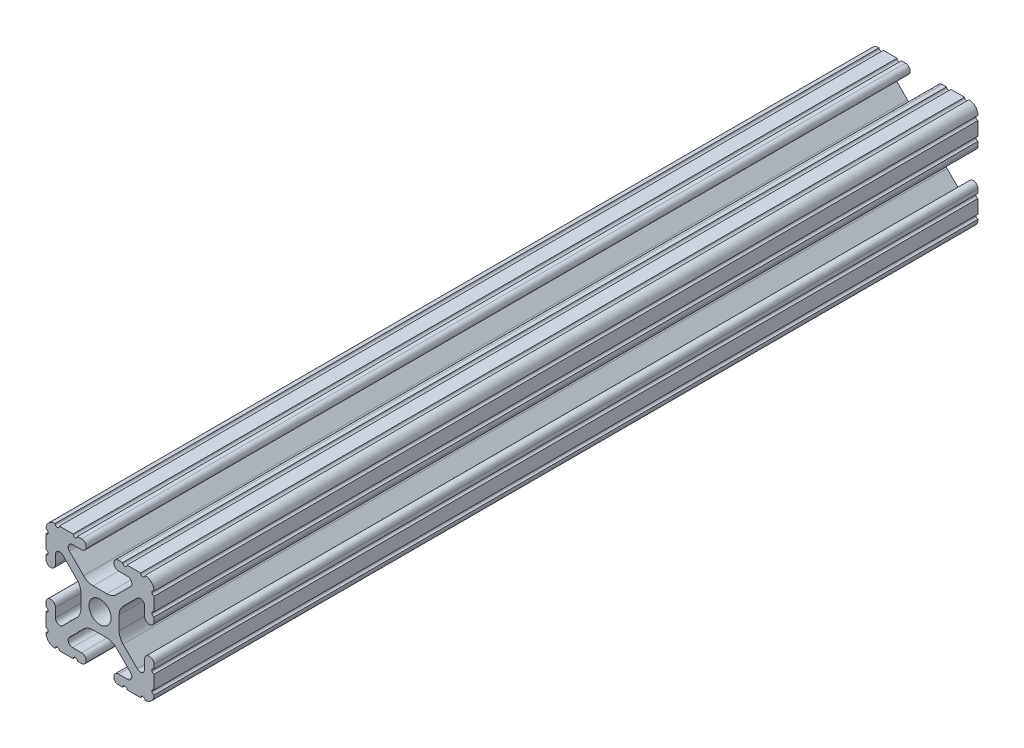
from build123d import *

# Parameters (mm, degrees)
SKETCH1_R           = 2.6035
BOSS_EXTRUDE1_DEPTH = 96.8756


with BuildPart() as part:
    # Sketch1 → Boss-Extrude1 (new body, symmetric)
    with BuildSketch(Plane(origin=(0, 0, -450.85), x_dir=(-1, 0, 0), z_dir=(0, 0, -1))):
        with BuildLine():
            Line((12.7, -9.5504), (12.7, -6.3330836))
            ThreePointArc((12.7, -6.3330836), (12.192, -5.8250836), (12.7, -5.3170836))
            Line((12.7, -5.3170836), (12.7, -4.3434))
            ThreePointArc((12.7, -4.3434), (11.5951, -3.2385), (10.4902, -4.3434))
            Line((10.4902, -4.3434), (10.4902, -6.474794456))
            ThreePointArc((10.4902, -6.474794456), (9.863006367, -7.413456061), (8.75577951, -7.193214945))
            Line((8.75577951, -7.193214945), (5.42573597, -3.863171405))
            ThreePointArc((5.42573597, -3.863171405), (4.737482484, -2.833127272), (4.4958, -1.618107374))
            Line((4.4958, -1.618107374), (4.4958, 1.618107374))
            ThreePointArc((4.4958, 1.618107374), (4.737482484, 2.833127272), (5.42573597, 3.863171405))
            Line((5.42573597, 3.863171405), (8.75577951, 7.193214945))
            ThreePointArc((8.75577951, 7.193214945), (9.863006367, 7.413456061), (10.4902, 6.474794456))
            Line((10.4902, 6.474794456), (10.4902, 4.343399971))
            ThreePointArc((10.4902, 4.343399971), (11.5951, 3.238499971), (12.7, 4.343399971))
            Line((12.7, 4.343399971), (12.7, 5.3170836))
            ThreePointArc((12.7, 5.3170836), (12.192, 5.8250836), (12.7, 6.3330836))
            Line((12.7, 6.3330836), (12.7, 9.5504))
            ThreePointArc((12.7, 9.5504), (12.192000006, 10.058323491), (12.699846982, 10.566399977))
            ThreePointArc((12.699846982, 10.566399977), (12.082522516, 12.082522516), (10.566399977, 12.699846982))
            ThreePointArc((10.566399977, 12.699846982), (10.058323491, 12.192000006), (9.5504, 12.7))
            Line((9.5504, 12.7), (6.3330836, 12.7))
            ThreePointArc((6.3330836, 12.7), (5.8250836, 12.192), (5.3170836, 12.7))
            Line((5.3170836, 12.7), (4.3434, 12.7))
            ThreePointArc((4.3434, 12.7), (3.2385, 11.5951), (4.3434, 10.4902))
            Line((4.3434, 10.4902), (6.474794456, 10.4902))
            ThreePointArc((6.474794456, 10.4902), (7.413456061, 9.863006367), (7.193214945, 8.75577951))
            Line((7.193214945, 8.75577951), (3.863171405, 5.42573597))
            ThreePointArc((3.863171405, 5.42573597), (2.833127272, 4.737482484), (1.618107374, 4.4958))
            Line((1.618107374, 4.4958), (-1.618107374, 4.4958))
            ThreePointArc((-1.618107374, 4.4958), (-2.833127272, 4.737482484), (-3.863171405, 5.42573597))
            Line((-3.863171405, 5.42573597), (-7.193214945, 8.75577951))
            ThreePointArc((-7.193214945, 8.75577951), (-7.413456061, 9.863006367), (-6.474794456, 10.4902))
            Line((-6.474794456, 10.4902), (-4.343399971, 10.4902))
            ThreePointArc((-4.343399971, 10.4902), (-3.238499971, 11.5951), (-4.343399971, 12.7))
            Line((-4.343399971, 12.7), (-5.3170836, 12.7))
            ThreePointArc((-5.3170836, 12.7), (-5.8250836, 12.192), (-6.3330836, 12.7))
            Line((-6.3330836, 12.7), (-9.5504, 12.7))
            ThreePointArc((-9.5504, 12.7), (-10.058323491, 12.192000006), (-10.566399977, 12.699846982))
            ThreePointArc((-10.566399977, 12.699846982), (-12.082522516, 12.082522516), (-12.699846982, 10.566399977))
            ThreePointArc((-12.699846982, 10.566399977), (-12.192000006, 10.058323491), (-12.7, 9.5504))
            Line((-12.7, 9.5504), (-12.7, 6.3330836))
            ThreePointArc((-12.7, 6.3330836), (-12.192, 5.8250836), (-12.7, 5.3170836))
            Line((-12.7, 5.3170836), (-12.7, 4.3434))
            ThreePointArc((-12.7, 4.3434), (-11.5951, 3.2385), (-10.4902, 4.3434))
            Line((-10.4902, 4.3434), (-10.4902, 6.474794456))
            ThreePointArc((-10.4902, 6.474794456), (-9.863006367, 7.413456061), (-8.75577951, 7.193214945))
            Line((-8.75577951, 7.193214945), (-5.42573597, 3.863171405))
            ThreePointArc((-5.42573597, 3.863171405), (-4.737482484, 2.833127272), (-4.4958, 1.618107374))
            Line((-4.4958, 1.618107374), (-4.4958, -1.618107374))
            ThreePointArc((-4.4958, -1.618107374), (-4.737482484, -2.833127272), (-5.42573597, -3.863171405))
            Line((-5.42573597, -3.863171405), (-8.75577951, -7.193214945))
            ThreePointArc((-8.75577951, -7.193214945), (-9.863006367, -7.413456061), (-10.4902, -6.474794456))
            Line((-10.4902, -6.474794456), (-10.4902, -4.343399971))
            ThreePointArc((-10.4902, -4.343399971), (-11.5951, -3.238499971), (-12.7, -4.343399971))
            Line((-12.7, -4.343399971), (-12.7, -5.3170836))
            ThreePointArc((-12.7, -5.3170836), (-12.192, -5.8250836), (-12.7, -6.3330836))
            Line((-12.7, -6.3330836), (-12.7, -9.5504))
            ThreePointArc((-12.7, -9.5504), (-12.192000006, -10.058323491), (-12.699846982, -10.566399977))
            ThreePointArc((-12.699846982, -10.566399977), (-12.082522516, -12.082522516), (-10.566399977, -12.699846982))
            ThreePointArc((-10.566399977, -12.699846982), (-10.058323491, -12.192000006), (-9.5504, -12.7))
            Line((-9.5504, -12.7), (-6.3330836, -12.7))
            ThreePointArc((-6.3330836, -12.7), (-5.8250836, -12.192), (-5.3170836, -12.7))
            Line((-5.3170836, -12.7), (-4.3434, -12.7))
            ThreePointArc((-4.3434, -12.7), (-3.2385, -11.5951), (-4.3434, -10.4902))
            Line((-4.3434, -10.4902), (-6.474794456, -10.4902))
            ThreePointArc((-6.474794456, -10.4902), (-7.413456061, -9.863006367), (-7.193214945, -8.75577951))
            Line((-7.193214945, -8.75577951), (-3.863171405, -5.42573597))
            ThreePointArc((-3.863171405, -5.42573597), (-2.833127272, -4.737482484), (-1.618107374, -4.4958))
            Line((-1.618107374, -4.4958), (1.618107374, -4.4958))
            ThreePointArc((1.618107374, -4.4958), (2.833127272, -4.737482484), (3.863171405, -5.42573597))
            Line((3.863171405, -5.42573597), (7.193214945, -8.75577951))
            ThreePointArc((7.193214945, -8.75577951), (7.413456061, -9.863006367), (6.474794456, -10.4902))
            Line((6.474794456, -10.4902), (4.343399971, -10.4902))
            ThreePointArc((4.343399971, -10.4902), (3.238499971, -11.5951), (4.343399971, -12.7))
            Line((4.343399971, -12.7), (5.3170836, -12.7))
            ThreePointArc((5.3170836, -12.7), (5.8250836, -12.192), (6.3330836, -12.7))
            Line((6.3330836, -12.7), (9.5504, -12.7))
            ThreePointArc((9.5504, -12.7), (10.058323491, -12.192000006), (10.566399977, -12.699846982))
            ThreePointArc((10.566399977, -12.699846982), (12.082522516, -12.082522516), (12.699846982, -10.566399977))
            ThreePointArc((12.699846982, -10.566399977), (12.192000006, -10.058323491), (12.7, -9.5504))
        make_face()
        Circle(SKETCH1_R, mode=Mode.SUBTRACT)
    extrude(amount=BOSS_EXTRUDE1_DEPTH, both=True)


solid = part.part
